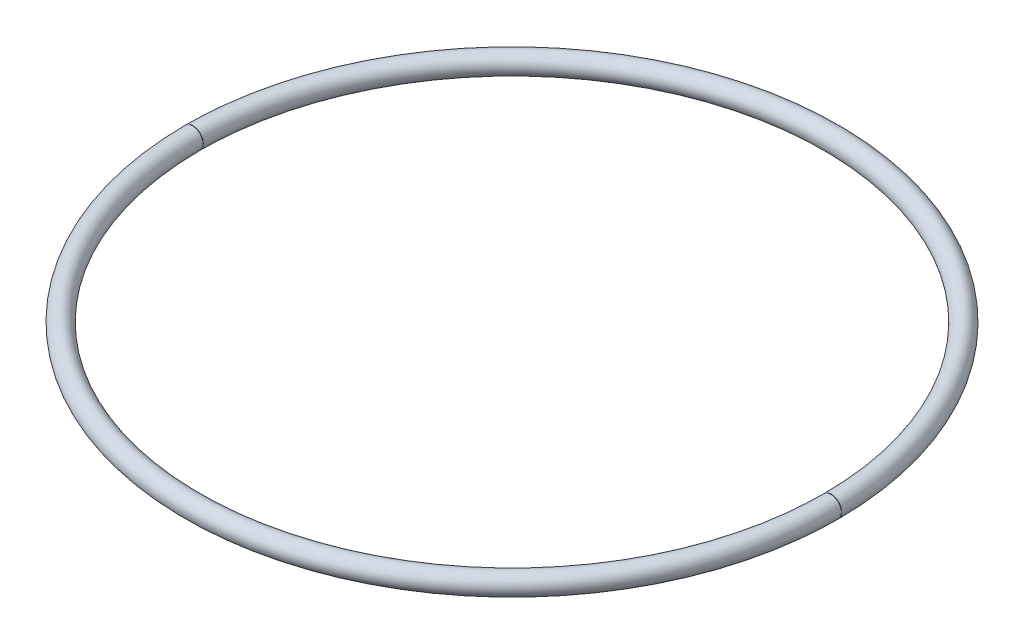
from build123d import *

# Parameters (mm, degrees)
SWEEP2_PROFILE_R        = 25.4
SHELL1_T                = -3.175
SKETCH25_W              = 101.6
SKETCH25_H              = 0.732692402
CUT_EXTRUDE1_DEPTH      = 1146.264354452
CUT_EXTRUDE1_DEPTH_BACK = 1146.264354452


with BuildPart() as part:
    # Sweep2: sweep along a path in Sketch24
    with BuildLine(Plane(origin=(0, 0, 0), x_dir=(1, 0, 0), z_dir=(0, 1, 0))) as sweep2_path:
        ThreePointArc((784.224899576, 0.396875), (-784.225, 0), (784.224899576, -0.396875))
    # Sweep2 profile (on start of the path) → Sweep2 (sweep)
    with BuildSketch(Plane(origin=(784.224899576, 0, -0.396875), x_dir=(-0.9999998719451145, 0, 0.0005060728747702501), z_dir=(-0.0005060728747702501, 0, -0.9999998719451145))):
        Circle(SWEEP2_PROFILE_R)
    sweep(path=sweep2_path.line)

    # Shell1
    shell1_openings = [part.faces().sort_by_distance(p)[0] for p in [
        (784.224899576, 0, 0.396875),
        (784.224899576, 0, -0.396875),
    ]]
    offset(amount=SHELL1_T, openings=shell1_openings, kind=Kind.INTERSECTION)

    # Sketch25 → Cut-Extrude1 (cut, two sides)
    with BuildSketch(Plane(origin=(0, 0, 0), x_dir=(1, 0, 0), z_dir=(0, 1, 0))) as cut_extrude1_sk:
        with Locations((-774.7, 0)):
            Rectangle(SKETCH25_W, SKETCH25_H)
    extrude(amount=CUT_EXTRUDE1_DEPTH, mode=Mode.SUBTRACT)
    extrude(cut_extrude1_sk.sketch, amount=-CUT_EXTRUDE1_DEPTH_BACK, mode=Mode.SUBTRACT)


with BuildPart() as cut_extrude1_piece_1:
    # of the separate pieces the step leaves, piece 1, a body of its own (cut_extrude1_pieces)
    add(part.part.solids().sort_by_distance((-758.824911568, 0, 0.366346201))[0])


with BuildPart() as cut_extrude1_piece_2:
    # of the separate pieces the step leaves, piece 2, a body of its own (cut_extrude1_pieces)
    add(part.part.solids().sort_by_distance((758.824902829, 0, -0.384020749))[0])


solid = Compound([cut_extrude1_piece_1.part, cut_extrude1_piece_2.part])
